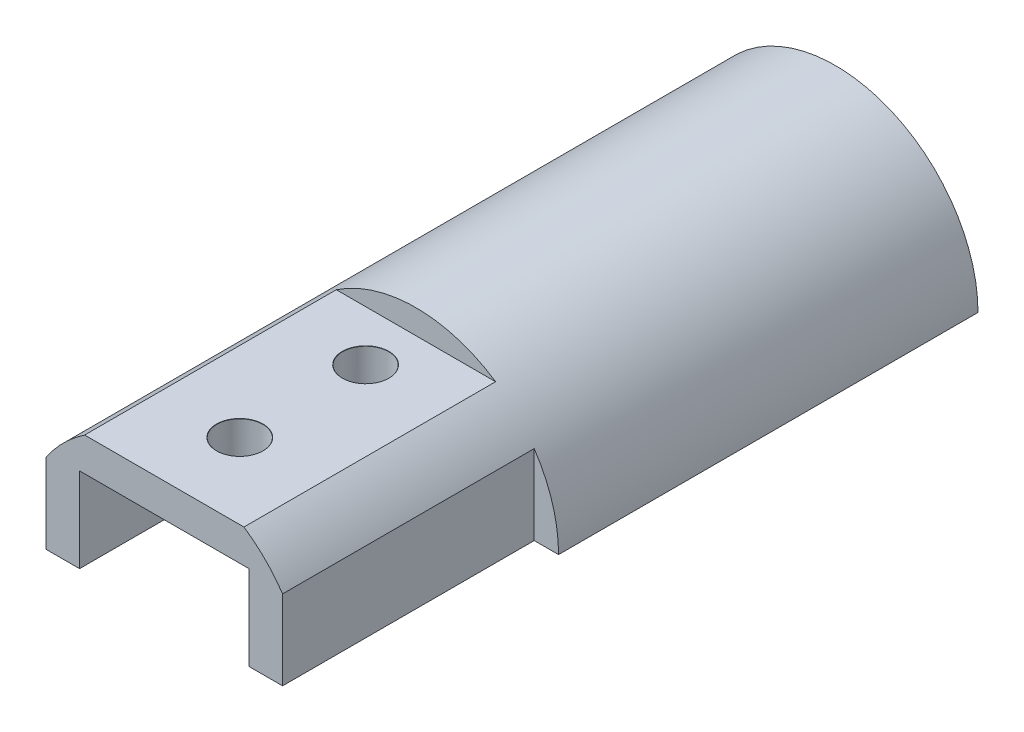
from build123d import *

# Parameters (mm, degrees)
SKETCH_1_R                     = 17
EXTRUDE_1_DEPTH                = 3
SKETCH_2_R                     = 17
SKETCH_2_R_2                   = 15
EXTRUDE_2_DEPTH                = 40
SKETCH_3_R                     = 5
CUT_EXTRUDE_1_DEPTH            = 4
SKETCH_4_R                     = 17
EXTRUDE_3_DEPTH                = 7
SKETCH_5_W                     = 20.2
SKETCH_5_H                     = 20.2
EXTRUDE_4_DEPTH                = 30
HOLE_WIZARD_M5_2_D             = 5.5
HOLE_WIZARD_M5_2_CSINK_D       = 5.55
HOLE_WIZARD_M5_2_CSINK_ANGLE   = 90
HOLE_WIZARD_M2_5_2_D           = 2.9
HOLE_WIZARD_M2_5_2_DEPTH       = 3
HOLE_WIZARD_M2_5_2_CSINK_D     = 2.95
HOLE_WIZARD_M2_5_2_CSINK_ANGLE = 90
SKETCH_12_W                    = 47.187362465
SKETCH_12_H                    = 89.366632215
CUT_EXTRUDE_2_DEPTH            = 18


with BuildPart() as part:
    # 草图1 → 凸台-拉伸1 (new body)
    with BuildSketch(Plane.XY):
        Circle(SKETCH_1_R)
    extrude(amount=EXTRUDE_1_DEPTH)

    # 草图2 → 凸台-拉伸2 (add)
    with BuildSketch(Plane.XY.offset(3)):
        Circle(SKETCH_2_R)
        Circle(SKETCH_2_R_2, mode=Mode.SUBTRACT)
    extrude(amount=EXTRUDE_2_DEPTH)

    # 草图3 → 切除-拉伸1 (cut, through all)
    with BuildSketch(Plane.XY.offset(3)):
        Circle(SKETCH_3_R)
    extrude(amount=-CUT_EXTRUDE_1_DEPTH, mode=Mode.SUBTRACT)

    # 草图4 → 凸台-拉伸3 (add)
    with BuildSketch(Plane.XY.offset(43)):
        Circle(SKETCH_4_R)
        Polygon((-4.443145751, 10.1), (4.443145751, 10.1), (10.1, 4.443145751), (10.1, -4.443145751), (4.443145751, -10.1), (-4.443145751, -10.1), (-10.1, -4.443145751), (-10.1, 4.443145751), align=None, mode=Mode.SUBTRACT)
    extrude(amount=EXTRUDE_3_DEPTH)

    # 草图5 → 凸台-拉伸4 (add)
    with BuildSketch(Plane.XY.offset(50)):
        with BuildLine():
            Line((9.49684158, 14.1), (-9.49684158, 14.1))
            ThreePointArc((-9.49684158, 14.1), (-12.02081528, 12.02081528), (-14.1, 9.49684158))
            Line((-14.1, 9.49684158), (-14.1, -9.496842588))
            ThreePointArc((-14.1, -9.496842588), (-12.020815678, -12.020815678), (-9.496842588, -14.1))
            Line((-9.496842588, -14.1), (9.49684158, -14.1))
            ThreePointArc((9.49684158, -14.1), (12.02081528, -12.02081528), (14.1, -9.49684158))
            Line((14.1, -9.49684158), (14.1, 9.49684158))
            ThreePointArc((14.1, 9.49684158), (12.02081528, 12.02081528), (9.49684158, 14.1))
        make_face()
        Rectangle(SKETCH_5_W, SKETCH_5_H, mode=Mode.SUBTRACT)
    extrude(amount=EXTRUDE_4_DEPTH)

    # M5 间隙孔2 (through all)
    with Locations(Plane(origin=(0, 14.1, 0), x_dir=(1, 0, 0), z_dir=(0, 1, 0))):
        with Locations((0, -56), (0, -71)):
            CounterSinkHole(HOLE_WIZARD_M5_2_D / 2, HOLE_WIZARD_M5_2_CSINK_D / 2, counter_sink_angle=HOLE_WIZARD_M5_2_CSINK_ANGLE)

    # M2.5 间隙孔2
    with Locations(Plane.XY.offset(3)):
        with Locations((11, 0), (7.778174593, -7.778174593), (0, -11), (-7.778174593, -7.778174593), (-11, 0), (-7.778174593, 7.778174593), (0, 11), (7.778174593, 7.778174593)):
            CounterSinkHole(HOLE_WIZARD_M2_5_2_D / 2, HOLE_WIZARD_M2_5_2_CSINK_D / 2, depth=HOLE_WIZARD_M2_5_2_DEPTH, counter_sink_angle=HOLE_WIZARD_M2_5_2_CSINK_ANGLE)

    # 草图12 → 切除-拉伸2 (cut)
    with BuildSketch(Plane(origin=(0, 0, 0), x_dir=(1, 0, 0), z_dir=(0, 1, 0))):
        with Locations((-0.779036645, -41.61129095)):
            Rectangle(SKETCH_12_W, SKETCH_12_H)
    extrude(amount=-CUT_EXTRUDE_2_DEPTH, mode=Mode.SUBTRACT)


solid = part.part
